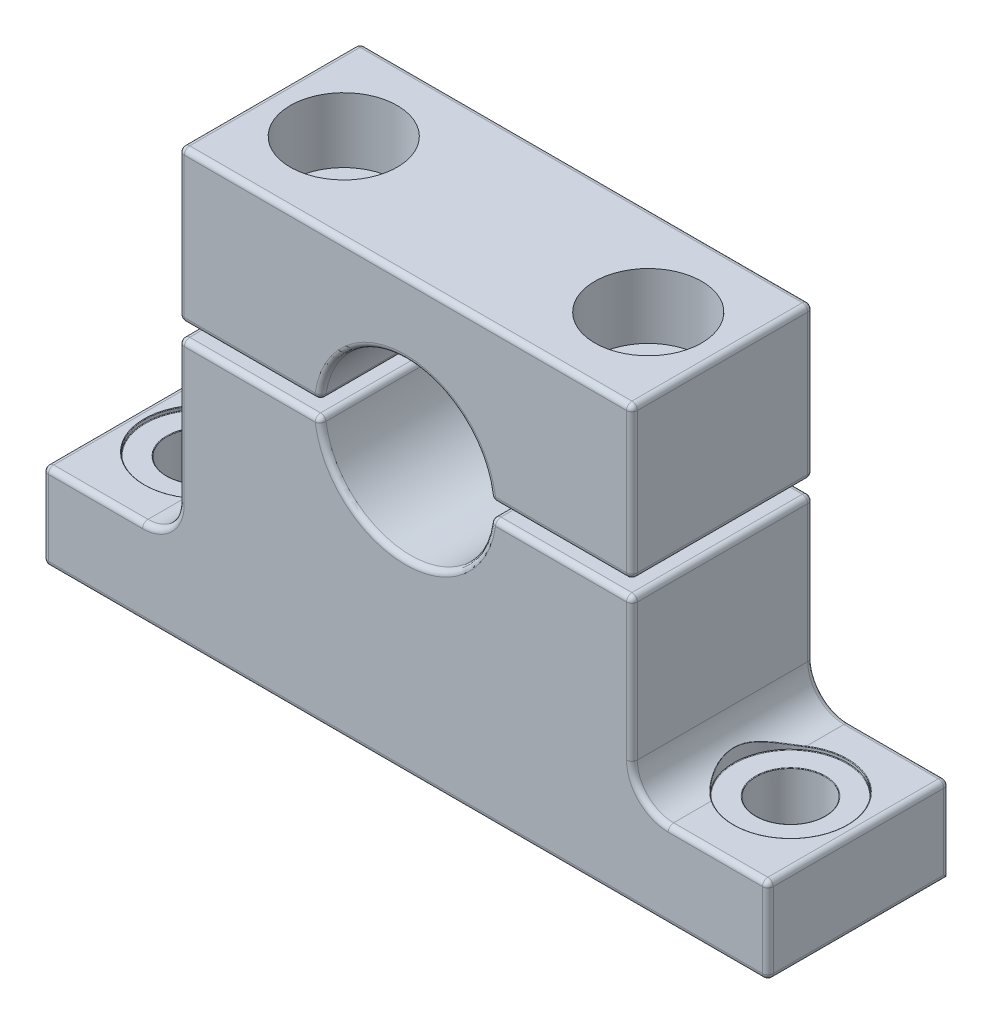
from build123d import *

# Parameters (mm, degrees)
BOSS_EXTRUDE1_DEPTH   = 12.7
BOSS_EXTRUDE1_2_DEPTH = 12.7
SKETCH4_R             = 2.413
CUT_EXTRUDE1_DEPTH    = 31.1625
SKETCH8_R             = 3.9751
CUT_EXTRUDE3_DEPTH    = 12.7635
SKETCH10_R            = 2.3368
CUT_EXTRUDE4_DEPTH    = 31.1625
SKETCH12_R            = 3.7465
CUT_EXTRUDE5_DEPTH    = 4.5466
FILLET1_R             = 0.381
FILLET2_R             = 0.381
FILLET3_R             = 0.0381


with BuildPart() as part:
    # Sketch3 → Boss-Extrude1 (new body)
    with BuildSketch(Plane.XY):
        with BuildLine():
            Line((-15.875, 30.1625), (15.875, 30.1625))
            Line((15.875, 30.1625), (15.875, 19.558))
            Line((15.875, 19.558), (5.978455988, 19.558))
            ThreePointArc((5.978455988, 19.558), (0, 25.05), (-5.978455988, 19.558))
            Line((-5.978455988, 19.558), (-15.875, 19.558))
            Line((-15.875, 19.558), (-15.875, 30.1625))
        make_face()
    extrude(amount=-BOSS_EXTRUDE1_DEPTH)


with BuildPart() as body_2:
    # Sketch3 → Boss-Extrude1 2 (new body)
    with BuildSketch(Plane.XY):
        with BuildLine():
            Line((-15.875, 18.542), (-15.875, 8.5725))
            ThreePointArc((-15.875, 8.5725), (-16.618948776, 6.776448776), (-18.415, 6.0325))
            Line((-18.415, 6.0325), (-25.4, 6.0325))
            Line((-25.4, 6.0325), (-25.4, 0))
            Line((-25.4, 0), (25.4, 0))
            Line((25.4, 0), (25.4, 6.0325))
            Line((25.4, 6.0325), (18.415, 6.0325))
            ThreePointArc((18.415, 6.0325), (16.618948776, 6.776448776), (15.875, 8.5725))
            Line((15.875, 8.5725), (15.875, 18.542))
            Line((15.875, 18.542), (5.978455988, 18.542))
            ThreePointArc((5.978455988, 18.542), (0, 13.05), (-5.978455988, 18.542))
            Line((-5.978455988, 18.542), (-15.875, 18.542))
        make_face()
    extrude(amount=-BOSS_EXTRUDE1_2_DEPTH)

    # Sketch4 → Cut-Extrude1 (cut, through all)
    with BuildSketch(Plane.XZ):
        with Locations((-20.6375, -6.35)):
            Circle(SKETCH4_R)
        with Locations((20.6375, -6.35)):
            Circle(SKETCH4_R)
    extrude(amount=-CUT_EXTRUDE1_DEPTH, mode=Mode.SUBTRACT)

    # Sketch8 → Cut-Extrude3 (cut)
    with BuildSketch(Plane(origin=(0, 18.542, 0), x_dir=(1, 0, 0), z_dir=(0, 1, 0))):
        with Locations((-20.6375, 6.35)):
            Circle(SKETCH8_R)
        with Locations((20.6375, 6.35)):
            Circle(SKETCH8_R)
    extrude(amount=-CUT_EXTRUDE3_DEPTH, mode=Mode.SUBTRACT)


with BuildPart() as cut_extrude4_tool:
    # Sketch10 → Cut-Extrude4 (new body, through all)
    with BuildSketch(Plane(origin=(0, 30.1625, 0), x_dir=(1, 0, 0), z_dir=(0, 1, 0))):
        with Locations((10.668, 6.35)):
            Circle(SKETCH10_R)
        with Locations((-10.668, 6.35)):
            Circle(SKETCH10_R)
    extrude(amount=-CUT_EXTRUDE4_DEPTH)


with BuildPart() as part_1:
    add(part.part)

    # Cut-Extrude4: cut by cut_extrude4_tool
    add(cut_extrude4_tool.part, mode=Mode.SUBTRACT)

    # Sketch12 → Cut-Extrude5 (cut)
    with BuildSketch(Plane(origin=(0, 30.1625, 0), x_dir=(1, 0, 0), z_dir=(0, 1, 0))):
        with Locations((10.668, 6.35)):
            Circle(SKETCH12_R)
        with Locations((-10.668, 6.35)):
            Circle(SKETCH12_R)
    extrude(amount=-CUT_EXTRUDE5_DEPTH, mode=Mode.SUBTRACT)

    # Fillet1
    fillet1_edges = [part_1.edges().sort_by_distance(p)[0] for p in [
        (0, 25.05, -12.7),
        (-15.875, 30.1625, -6.35),
        (15.875, 30.1625, -6.35),
        (15.875, 19.558, -6.35),
        (5.978455988, 19.558, -6.35),
        (-5.978455988, 19.558, -6.35),
        (-15.875, 19.558, -6.35),
        (10.926727994, 19.558, -12.7),
        (15.875, 24.86025, -12.7),
        (0, 30.1625, -12.7),
        (-15.875, 24.86025, -12.7),
        (0, 30.1625, 0),
        (15.875, 24.86025, 0),
        (10.926727994, 19.558, 0),
        (-10.926727994, 19.558, -12.7),
        (0, 25.05, 0),
        (-10.926727994, 19.558, 0),
        (-15.875, 24.86025, 0),
    ]]
    fillet(fillet1_edges, radius=FILLET1_R)


with BuildPart() as body_2_1:
    add(body_2.part)

    # Cut-Extrude4: cut by cut_extrude4_tool
    add(cut_extrude4_tool.part, mode=Mode.SUBTRACT)

    # Fillet2
    fillet2_edges = [body_2_1.edges().sort_by_distance(p)[0] for p in [
        (-16.618948776, 6.776448776, -12.7),
        (0, 13.05, 0),
        (10.926727994, 18.542, 0),
        (15.875, 13.55725, 0),
        (16.618948776, 6.776448776, 0),
        (21.9075, 6.0325, 0),
        (25.4, 3.01625, 0),
        (-21.9075, 6.0325, -12.7),
        (0, 0, 0),
        (-25.4, 3.01625, 0),
        (-21.9075, 6.0325, 0),
        (-16.618948776, 6.776448776, 0),
        (-15.875, 13.55725, 0),
        (-10.926727994, 18.542, 0),
        (-25.4, 3.01625, -12.7),
        (-5.978455988, 18.542, -6.35),
        (5.978455988, 18.542, -6.35),
        (15.875, 18.542, -6.35),
        (25.4, 6.0325, -6.35),
        (25.4, 0, -6.35),
        (-25.4, 0, -6.35),
        (-25.4, 6.0325, -6.35),
        (-15.875, 18.542, -6.35),
        (25.4, 3.01625, -12.7),
        (21.9075, 6.0325, -12.7),
        (16.618948776, 6.776448776, -12.7),
        (15.875, 13.55725, -12.7),
        (10.926727994, 18.542, -12.7),
        (0, 13.05, -12.7),
        (-10.926727994, 18.542, -12.7),
        (-15.875, 13.55725, -12.7),
    ]]
    fillet(fillet2_edges, radius=FILLET2_R)

    # Fillet3
    fillet3_edges = [body_2_1.edges().sort_by_distance(p)[0] for p in [
        (-17.127675346, 6.382889222, -4.48384065),
        (-24.6126, 6.0325, -6.35),
        (-24.6126, 5.7785, -6.35),
        (-23.0505, 5.7785, -6.35),
        (22.503881561, 6.0325, -2.840293477),
        (16.6624, 6.734024207, -6.35),
        (18.2245, 5.7785, -6.35),
        (16.6624, 5.7785, -6.35),
    ]]
    fillet(fillet3_edges, radius=FILLET3_R)


solid = Compound([part_1.part, body_2_1.part])
